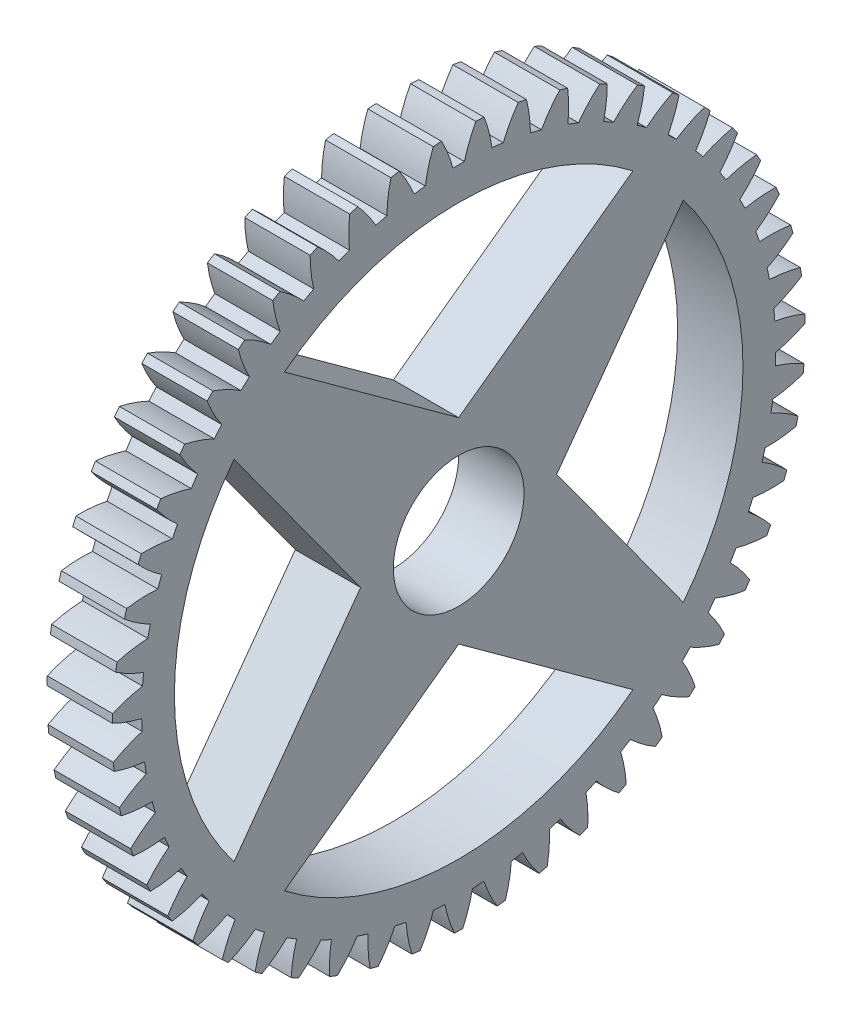
from build123d import *

# Parameters (mm, degrees)
BASPROSKE_W             = 5
BASPROSKE_H             = 26.5
TOOTHCUT_DEPTH          = 38.808729151
TEETHCUTS_COUNT         = 51
TEETHCUTS_ANGLE         = 352.941176471
BORSKE_R                = 2.5
BORE_DEPTH              = 50.0000508
BOSS_EXTRUDE1_DEPTH     = 5
SKETCH2_R               = 5
CUT_EXTRUDE1_DEPTH      = 38.805443909
CUT_EXTRUDE1_DEPTH_BACK = 38.805443909


with BuildPart() as part:
    # BasProSke → Base-Revolve (revolve)
    with BuildSketch(Plane(origin=(0, 0, 0), x_dir=(1, 0, 0), z_dir=(0, 1, 0)), mode=Mode.PRIVATE) as base_revolve_sk:
        with Locations((2.5, 13.25)):
            Rectangle(BASPROSKE_W, BASPROSKE_H)
    revolve(base_revolve_sk.sketch.rotate(Axis((-10, 0, 0), (1, 0, 0)), 180), axis=Axis((-10, 0, 0), (1, 0, 0)))

    # TooCutSke → ToothCut (cut, through all)
    with BuildSketch(Plane(origin=(0, 0, 0), x_dir=(0, 0, -1), z_dir=(1, 0, 0))):
        with BuildLine():
            ThreePointArc((0.436787053, 24.24506585), (0, 24.249), (-0.436787053, 24.24506585))
            ThreePointArc((-0.436787053, 24.24506585), (-0.815323051, 25.395091367), (-1.327457799, 26.49216301))
            ThreePointArc((-1.327457799, 26.49216301), (0, 26.5254), (1.327457799, 26.49216301))
            ThreePointArc((1.327457799, 26.49216301), (0.815323051, 25.395091367), (0.436787053, 24.24506585))
        make_face()
    toothcut = extrude(amount=TOOTHCUT_DEPTH, mode=Mode.SUBTRACT)

    # TeethCuts: ToothCut ×51 about axis
    teethcuts_axis = Axis((-10, 0, 0), (1, 0, 0))
    for i in range(1, TEETHCUTS_COUNT):
        add(toothcut.rotate(teethcuts_axis, i * TEETHCUTS_ANGLE / (TEETHCUTS_COUNT - 1)), mode=Mode.SUBTRACT)

    # BorSke → Bore (cut, symmetric)
    with BuildSketch(Plane(origin=(0, 0, 0), x_dir=(0, 0, -1), z_dir=(1, 0, 0))):
        with Locations(Location((0, 0, 0), (0, 0, 180))):
            Circle(BORSKE_R)
    extrude(amount=BORE_DEPTH, both=True, mode=Mode.SUBTRACT)

    # Sketch1 → Boss-Extrude1 (add)
    with BuildSketch(Plane(origin=(5, 0, 0), x_dir=(0, 0, -1), z_dir=(1, 0, 0))):
        with BuildLine():
            ThreePointArc((2.5, 0), (2.236067977, 1.118033989), (1.5, 2))
            Line((1.5, 2), (1.5, -2))
            ThreePointArc((1.5, -2), (2.236067977, -1.118033989), (2.5, 0))
        make_face()
    extrude(amount=-BOSS_EXTRUDE1_DEPTH)

    # Sketch2 → Cut-Extrude1 (cut, two sides)
    with BuildSketch(Plane.ZY) as cut_extrude1_sk:
        with BuildLine():
            Line((7.5, 0), (17.184985558, -13.330239022))
            ThreePointArc((17.184985558, -13.330239022), (20.576385153, -7.044953872), (21.749, 0))
            ThreePointArc((21.749, 0), (20.576385153, 7.044953872), (17.184985558, 13.330239022))
            Line((17.184985558, 13.330239022), (7.5, 0))
        make_face()
        with BuildLine():
            Line((-13.330239022, 17.184985558), (0, 7.5))
            Line((0, 7.5), (13.330239022, 17.184985558))
            ThreePointArc((13.330239022, 17.184985558), (0, 21.749), (-13.330239022, 17.184985558))
        make_face()
        with BuildLine():
            Line((-17.184985558, -13.330239022), (-7.5, 0))
            Line((-7.5, 0), (-17.184985558, 13.330239022))
            ThreePointArc((-17.184985558, 13.330239022), (-21.749, 0), (-17.184985558, -13.330239022))
        make_face()
        with BuildLine():
            Line((13.330239022, -17.184985558), (0, -7.5))
            Line((0, -7.5), (-13.330239022, -17.184985558))
            ThreePointArc((-13.330239022, -17.184985558), (0, -21.749), (13.330239022, -17.184985558))
        make_face()
        Circle(SKETCH2_R)
    extrude(amount=CUT_EXTRUDE1_DEPTH, mode=Mode.SUBTRACT)
    extrude(cut_extrude1_sk.sketch, amount=-CUT_EXTRUDE1_DEPTH_BACK, mode=Mode.SUBTRACT)


solid = part.part
